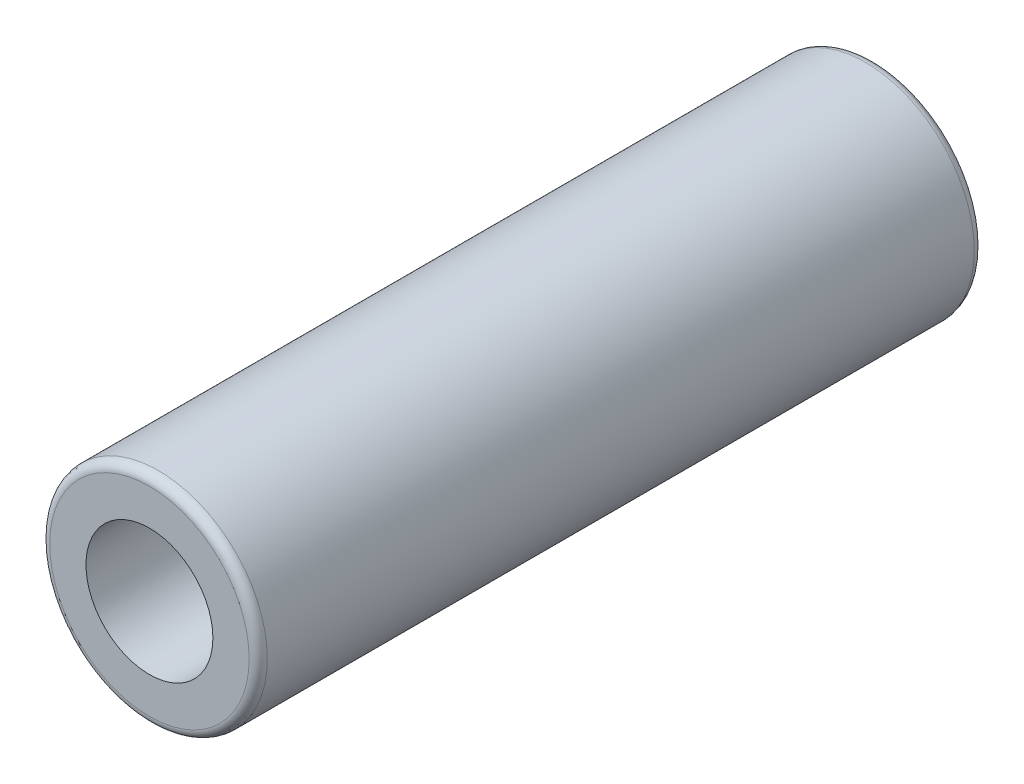
from build123d import *

# Parameters (mm, degrees)
SKETCH1_R           = 6
SKETCH1_R_2         = 3.5
BOSS_EXTRUDE1_DEPTH = 40
FILLET1_R           = 0.5
FILLET2_R           = 0.5


with BuildPart() as part:
    # Sketch1 → Boss-Extrude1 (new body)
    with BuildSketch(Plane.XY):
        Circle(SKETCH1_R)
        Circle(SKETCH1_R_2, mode=Mode.SUBTRACT)
    extrude(amount=BOSS_EXTRUDE1_DEPTH)

    # Fillet1
    fillet1_edges = [part.edges().sort_by_distance(p)[0] for p in [
        (-6, 0, 40),
    ]]
    fillet(fillet1_edges, radius=FILLET1_R)

    # Fillet2
    fillet2_edges = [part.edges().sort_by_distance(p)[0] for p in [
        (-6, 0, 0),
    ]]
    fillet(fillet2_edges, radius=FILLET2_R)


solid = part.part
